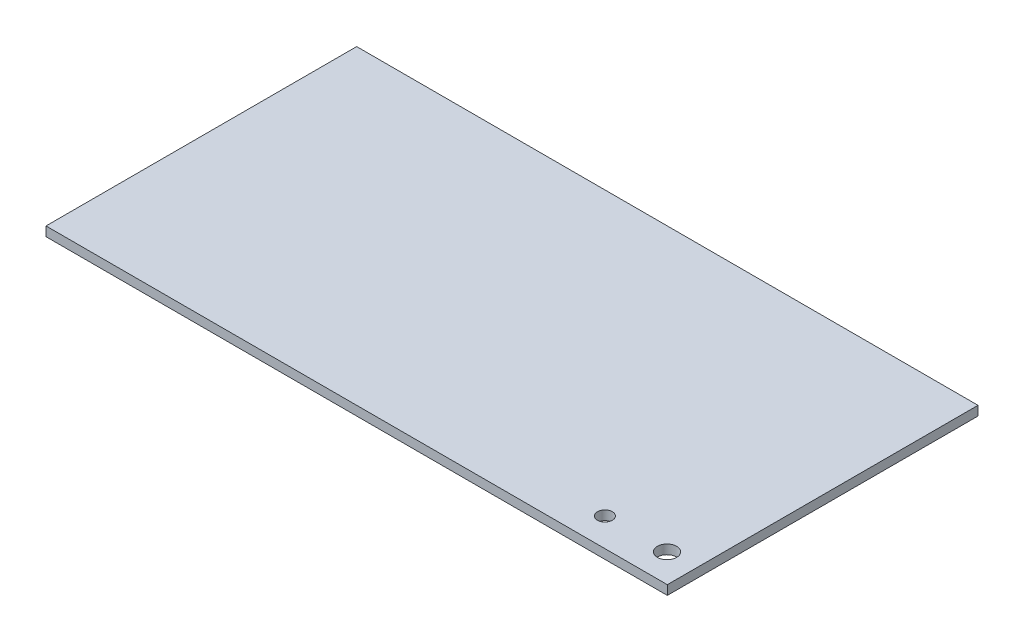
from build123d import *

# Parameters (mm, degrees)
SKETCH1_W           = 254
SKETCH1_H           = 127
BOSS_EXTRUDE1_DEPTH = 3.81
SKETCH2_R           = 3.048
SKETCH2_R_2         = 3.937
CUT_EXTRUDE1_DEPTH  = 25.4


with BuildPart() as part:
    # Sketch1 → Boss-Extrude1 (new body)
    with BuildSketch(Plane(origin=(0, 0, 0), x_dir=(1, 0, 0), z_dir=(0, 1, 0))):
        with Locations((4587.285714286, 2322.214285714)):
            Rectangle(SKETCH1_W, SKETCH1_H)
    extrude(amount=BOSS_EXTRUDE1_DEPTH)

    # Sketch2 → Cut-Extrude1 (cut)
    with BuildSketch(Plane(origin=(0, 3.81, 0), x_dir=(1, 0, 0), z_dir=(0, 1, 0))):
        with Locations((4677.201714286, 2270.271285714)):
            Circle(SKETCH2_R)
        with Locations((4702.601714286, 2270.271285714)):
            Circle(SKETCH2_R_2)
    extrude(amount=-CUT_EXTRUDE1_DEPTH, mode=Mode.SUBTRACT)


solid = part.part
